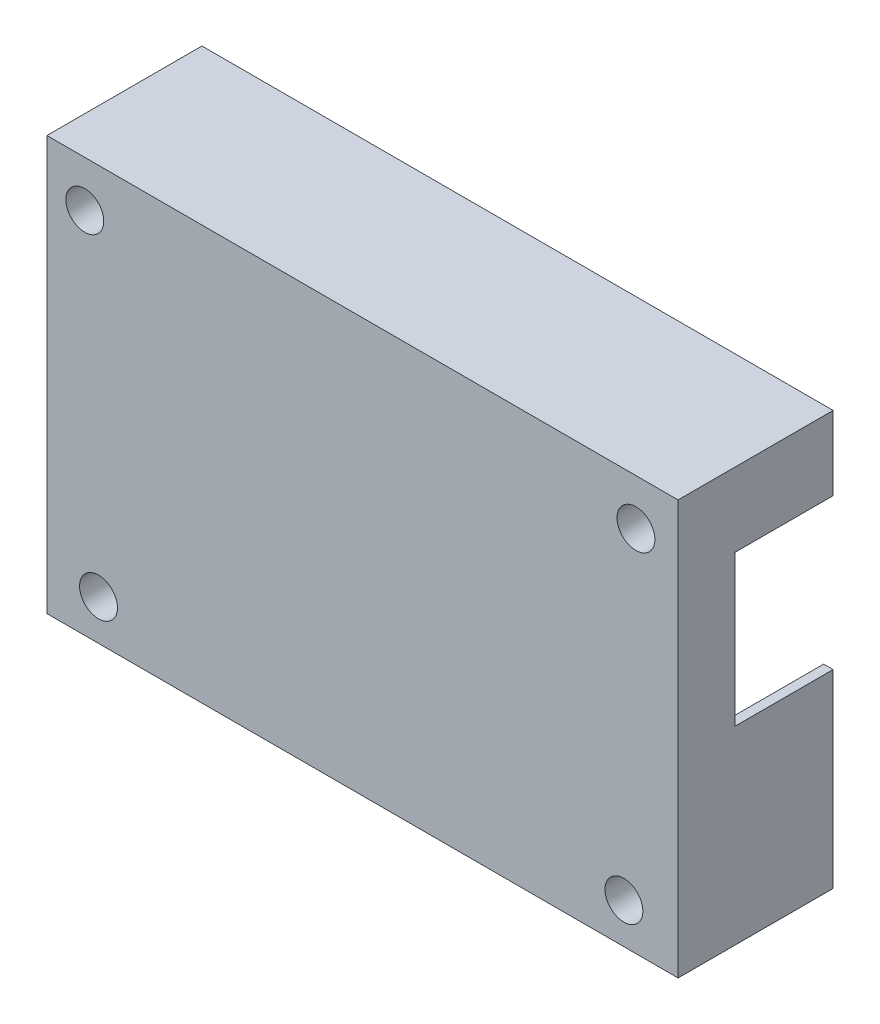
from build123d import *

# Parameters (mm, degrees)
SKETCH3_W           = 6
SKETCH3_H           = 6.8
SKETCH3_R           = 2
SKETCH3_W_2         = 6.5
SKETCH3_W_3         = 8
SKETCH3_H_2         = 6
BOSS_EXTRUDE1_DEPTH = 8.25
BOSS_EXTRUDE2_DEPTH = 2.12
BOSS_EXTRUDE3_START = 8.25
SKETCH3_4_W         = 1
SKETCH3_4_H         = 15.9
SKETCH3_4_W_2       = 6
SKETCH3_4_H_2       = 6.8
SKETCH3_4_R         = 2
SKETCH3_4_W_3       = 6.5
SKETCH3_4_W_4       = 8
SKETCH3_4_H_3       = 6
BOSS_EXTRUDE3_DEPTH = 5
SKETCH4_W           = 66.65
SKETCH4_H           = 43.72
SKETCH4_R           = 2
BOSS_EXTRUDE4_DEPTH = 1
FILLET1_R           = 1


with BuildPart() as part:
    # Sketch3 → Boss-Extrude1 (new body)
    with BuildSketch(Plane.XY):
        with Locations((-29.325, 17.46)):
            Rectangle(SKETCH3_W, SKETCH3_H)
        with Locations((-29.325, 17.01)):
            Circle(SKETCH3_R, mode=Mode.SUBTRACT)
        Polygon((-33.325, 14.06), (-32.325, 14.06), (-32.325, 20.86), (-26.325, 20.86), (25.825, 20.86), (32.325, 20.86), (32.325, 14.06), (33.325, 14.06), (33.325, 21.86), (-33.325, 21.86), align=None)
        with Locations((29.075, 17.46)):
            Rectangle(SKETCH3_W_2, SKETCH3_H)
        with Locations((28.875, 17.01)):
            Circle(SKETCH3_R, mode=Mode.SUBTRACT)
        with Locations((28.325, -17.86)):
            Rectangle(SKETCH3_W_3, SKETCH3_H_2)
        with Locations((27.605, -17.61)):
            Circle(SKETCH3_R, mode=Mode.SUBTRACT)
        Polygon((-32.325, -14.86), (-32.325, -1.84), (-33.325, -1.84), (-33.325, -21.86), (33.325, -21.86), (33.325, -1.84), (32.325, -1.84), (32.325, -14.86), (32.325, -20.86), (24.325, -20.86), (-24.325, -20.86), (-32.325, -20.86), align=None)
        with Locations((-28.325, -17.86)):
            Rectangle(SKETCH3_W_3, SKETCH3_H_2)
        with Locations((-27.875, -17.61)):
            Circle(SKETCH3_R, mode=Mode.SUBTRACT)
    extrude(amount=BOSS_EXTRUDE1_DEPTH)

    # Sketch3_3 → Boss-Extrude2 (add)
    with BuildSketch(Plane.XY):
        Polygon((-33.325, 14.06), (-32.325, 14.06), (-32.325, 20.86), (-26.325, 20.86), (25.825, 20.86), (32.325, 20.86), (32.325, 14.06), (33.325, 14.06), (33.325, 21.86), (-33.325, 21.86), align=None)
        Polygon((-32.325, -14.86), (-32.325, -1.84), (-33.325, -1.84), (-33.325, -21.86), (33.325, -21.86), (33.325, -1.84), (32.325, -1.84), (32.325, -14.86), (32.325, -20.86), (24.325, -20.86), (-24.325, -20.86), (-32.325, -20.86), align=None)
    extrude(amount=-BOSS_EXTRUDE2_DEPTH)

    # Sketch3_4 → Boss-Extrude3 (add)
    with BuildSketch(Plane.XY.offset(BOSS_EXTRUDE3_START)):
        Polygon((-33.325, 14.06), (-32.325, 14.06), (-32.325, 20.86), (-26.325, 20.86), (25.825, 20.86), (32.325, 20.86), (32.325, 14.06), (33.325, 14.06), (33.325, 21.86), (-33.325, 21.86), align=None)
        Polygon((-32.325, -14.86), (-32.325, -1.84), (-33.325, -1.84), (-33.325, -21.86), (33.325, -21.86), (33.325, -1.84), (32.325, -1.84), (32.325, -14.86), (32.325, -20.86), (24.325, -20.86), (-24.325, -20.86), (-32.325, -20.86), align=None)
        with Locations((-32.825, 6.11)):
            Rectangle(SKETCH3_4_W, SKETCH3_4_H)
        with Locations((32.825, 6.11)):
            Rectangle(SKETCH3_4_W, SKETCH3_4_H)
        with Locations((-29.325, 17.46)):
            Rectangle(SKETCH3_4_W_2, SKETCH3_4_H_2)
        with Locations((-29.325, 17.01)):
            Circle(SKETCH3_4_R, mode=Mode.SUBTRACT)
        with Locations((29.075, 17.46)):
            Rectangle(SKETCH3_4_W_3, SKETCH3_4_H_2)
        with Locations((28.875, 17.01)):
            Circle(SKETCH3_4_R, mode=Mode.SUBTRACT)
        with Locations((28.325, -17.86)):
            Rectangle(SKETCH3_4_W_4, SKETCH3_4_H_3)
        with Locations((27.605, -17.61)):
            Circle(SKETCH3_4_R, mode=Mode.SUBTRACT)
        with Locations((-28.325, -17.86)):
            Rectangle(SKETCH3_4_W_4, SKETCH3_4_H_3)
        with Locations((-27.875, -17.61)):
            Circle(SKETCH3_4_R, mode=Mode.SUBTRACT)
    extrude(amount=BOSS_EXTRUDE3_DEPTH)

    # Sketch4 → Boss-Extrude4 (add)
    with BuildSketch(Plane.XY.offset(13.25)):
        Rectangle(SKETCH4_W, SKETCH4_H)
        with Locations((27.605, -17.61)):
            Circle(SKETCH4_R, mode=Mode.SUBTRACT)
        with Locations((28.875, 17.01)):
            Circle(SKETCH4_R, mode=Mode.SUBTRACT)
        with Locations((-29.325, 17.01)):
            Circle(SKETCH4_R, mode=Mode.SUBTRACT)
        with Locations((-27.875, -17.61)):
            Circle(SKETCH4_R, mode=Mode.SUBTRACT)
    extrude(amount=BOSS_EXTRUDE4_DEPTH)

    # Fillet1
    fillet1_edges = [part.edges().sort_by_distance(p)[0] for p in [
        (25.825, 14.06, 6.625),
        (-26.325, 14.06, 6.625),
        (-24.325, -14.86, 6.625),
        (24.325, -14.86, 6.625),
    ]]
    fillet(fillet1_edges, radius=FILLET1_R)


solid = part.part
